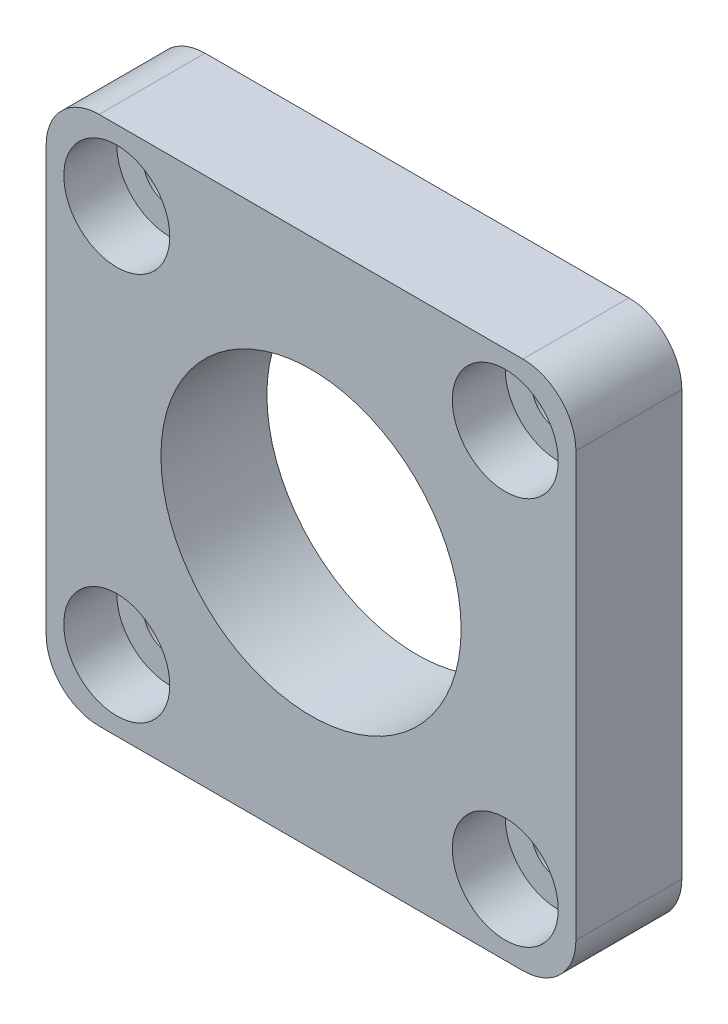
from build123d import *

# Parameters (mm, degrees)
SKETCH1_W           = 30
SKETCH1_H           = 30
SKETCH1_R           = 8.5
BOSS_EXTRUDE1_DEPTH = 6
SKETCH3_R           = 1.5
CUT_EXTRUDE2_DEPTH  = 7
SKETCH4_R           = 3
CUT_EXTRUDE3_DEPTH  = 3
FILLET1_R           = 3


with BuildPart() as part:
    # Sketch1 → Boss-Extrude1 (new body)
    with BuildSketch(Plane.XY):
        Rectangle(SKETCH1_W, SKETCH1_H)
        Circle(SKETCH1_R, mode=Mode.SUBTRACT)
    extrude(amount=BOSS_EXTRUDE1_DEPTH)

    # Sketch3 → Cut-Extrude2 (cut, through all)
    with BuildSketch(Plane.XY.offset(6)):
        with Locations((-11, 11)):
            Circle(SKETCH3_R)
        with Locations((11, 11)):
            Circle(SKETCH3_R)
        with Locations((11, -11)):
            Circle(SKETCH3_R)
        with Locations((-11, -11)):
            Circle(SKETCH3_R)
    extrude(amount=-CUT_EXTRUDE2_DEPTH, mode=Mode.SUBTRACT)

    # Sketch4 → Cut-Extrude3 (cut)
    with BuildSketch(Plane.XY.offset(6)):
        with Locations((-11, 11)):
            Circle(SKETCH4_R)
        with Locations((11, 11)):
            Circle(SKETCH4_R)
        with Locations((11, -11)):
            Circle(SKETCH4_R)
        with Locations((-11, -11)):
            Circle(SKETCH4_R)
    extrude(amount=-CUT_EXTRUDE3_DEPTH, mode=Mode.SUBTRACT)

    # Fillet1
    fillet1_edges = [part.edges().sort_by_distance(p)[0] for p in [
        (15, -15, 3),
        (-15, -15, 3),
        (-15, 15, 3),
        (15, 15, 3),
    ]]
    fillet(fillet1_edges, radius=FILLET1_R)


solid = part.part
